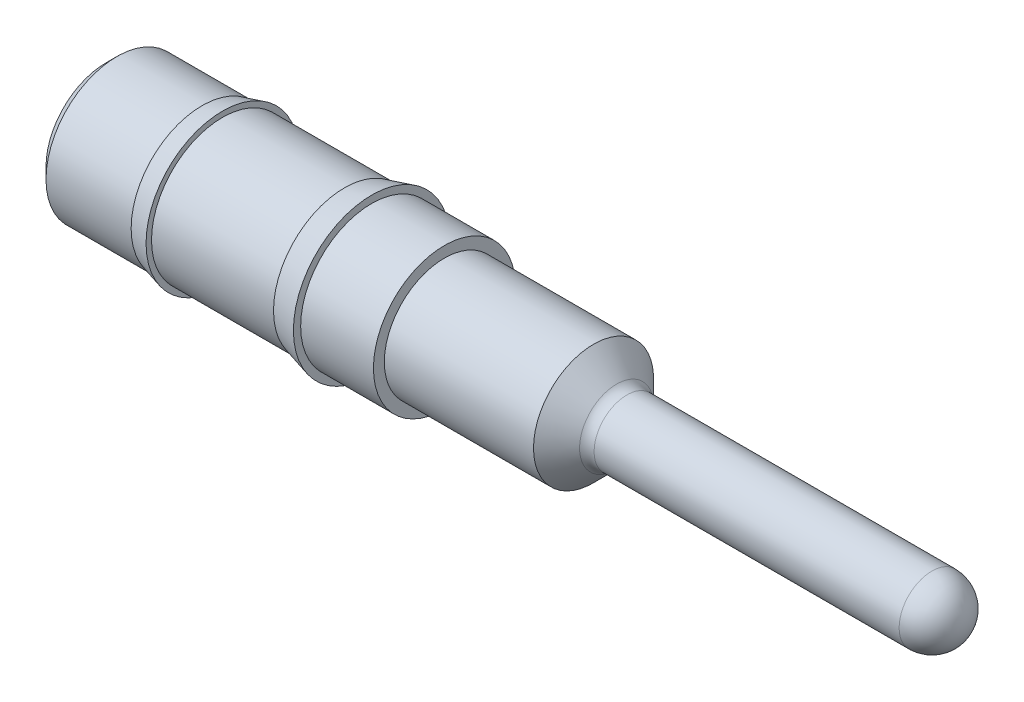
from build123d import *

# Parameters (mm, degrees)
HOLE1_D     = 0.7874
HOLE1_DEPTH = 2.1082
HOLE1_TIP   = 0.236558826
HOLE2_D     = 0.5588
HOLE2_DEPTH = 3.048
HOLE2_TIP   = 0.167880457


with BuildPart() as part:
    # Sketch1 → RevolutionAngle1 (revolve)
    with BuildSketch(Plane.XY):
        with BuildLine():
            Line((0, 0), (0, 0.4191))
            Line((0, 0.4191), (0.0762, 0.4953))
            Line((0.0762, 0.4953), (0.670608864, 0.4953))
            Line((0.670608864, 0.4953), (0.8128, 0.5334))
            Line((0.8128, 0.5334), (0.8128, 0.4953))
            Line((0.8128, 0.4953), (1.664611819, 0.4953))
            Line((1.664611819, 0.4953), (1.8542, 0.5461))
            Line((1.8542, 0.5461), (1.8542, 0.4953))
            Line((1.8542, 0.4953), (2.3622, 0.4953))
            Line((2.3622, 0.4953), (2.3622, 0.4191))
            Line((2.3622, 0.4191), (3.4036, 0.4191))
            Line((3.4036, 0.4191), (3.564342049, 0.258357951))
            ThreePointArc((3.564342049, 0.258357951), (3.597303461, 0.236333839), (3.636184098, 0.2286))
            Line((3.636184098, 0.2286), (5.7658, 0.2286))
            ThreePointArc((5.7658, 0.2286), (5.92744461, 0.16164461), (5.9944, 0))
            Line((5.9944, 0), (0, 0))
        make_face()
    revolve(axis=Axis((0, 0, 0), (1, 0, 0)))

    # Hole1
    with Locations(Plane.ZY):
        with Locations((0, 0)):
            Hole(HOLE1_D / 2, depth=HOLE1_DEPTH)
            with Locations((0, 0, -(HOLE1_DEPTH + HOLE1_TIP / 2))):  # 118° drill point
                Cone(0, HOLE1_D / 2, HOLE1_TIP, mode=Mode.SUBTRACT)

    # Hole2
    with Locations(Plane(origin=(0, 0, 0.3937), x_dir=(0, 0, 1), z_dir=(-1, 0, 0))):
        with Locations((-0.3937, 0)):
            Hole(HOLE2_D / 2, depth=HOLE2_DEPTH)
            with Locations((0, 0, -(HOLE2_DEPTH + HOLE2_TIP / 2))):  # 118° drill point
                Cone(0, HOLE2_D / 2, HOLE2_TIP, mode=Mode.SUBTRACT)


solid = part.part
